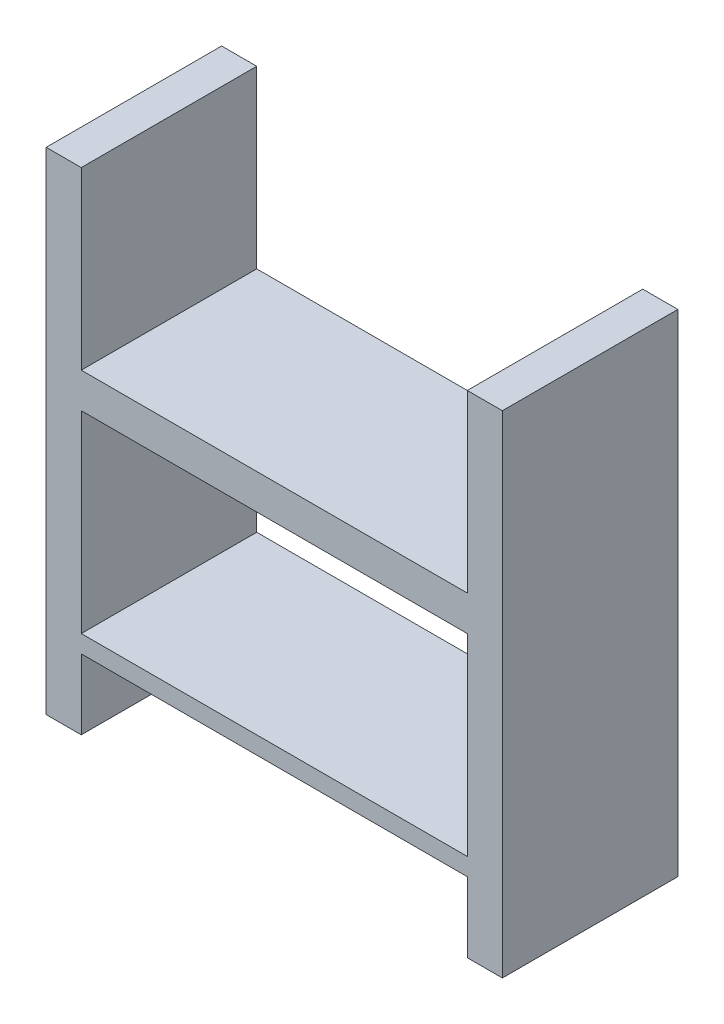
from build123d import *

# Parameters (mm, degrees)
SKETCH2_W           = 110
SKETCH2_H           = 55
BOSS_EXTRUDE1_DEPTH = 50


with BuildPart() as part:
    # Sketch2 → Boss-Extrude1 (new body)
    with BuildSketch(Plane.XY):
        Polygon((55, -45), (55, -25), (-55, -25), (-55, -45), (-65, -45), (-65, 45), (-65, 95), (-55, 95), (-55, 45), (55, 45), (55, 95), (65, 95), (65, 45), (65, -45), align=None)
        with Locations((0, 7.5)):
            Rectangle(SKETCH2_W, SKETCH2_H, mode=Mode.SUBTRACT)
    extrude(amount=BOSS_EXTRUDE1_DEPTH)


solid = part.part
